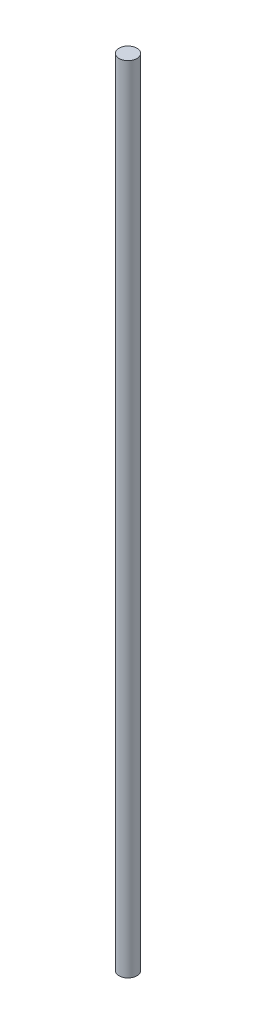
from build123d import *

# Parameters (mm, degrees)
SKETCH1_R           = 3.05
BOSS_EXTRUDE1_DEPTH = 270


with BuildPart() as part:
    # Sketch1 → Boss-Extrude1 (new body)
    with BuildSketch(Plane(origin=(0, 0, 0), x_dir=(1, 0, 0), z_dir=(0, 1, 0))):
        Circle(SKETCH1_R)
    extrude(amount=BOSS_EXTRUDE1_DEPTH)


solid = part.part
